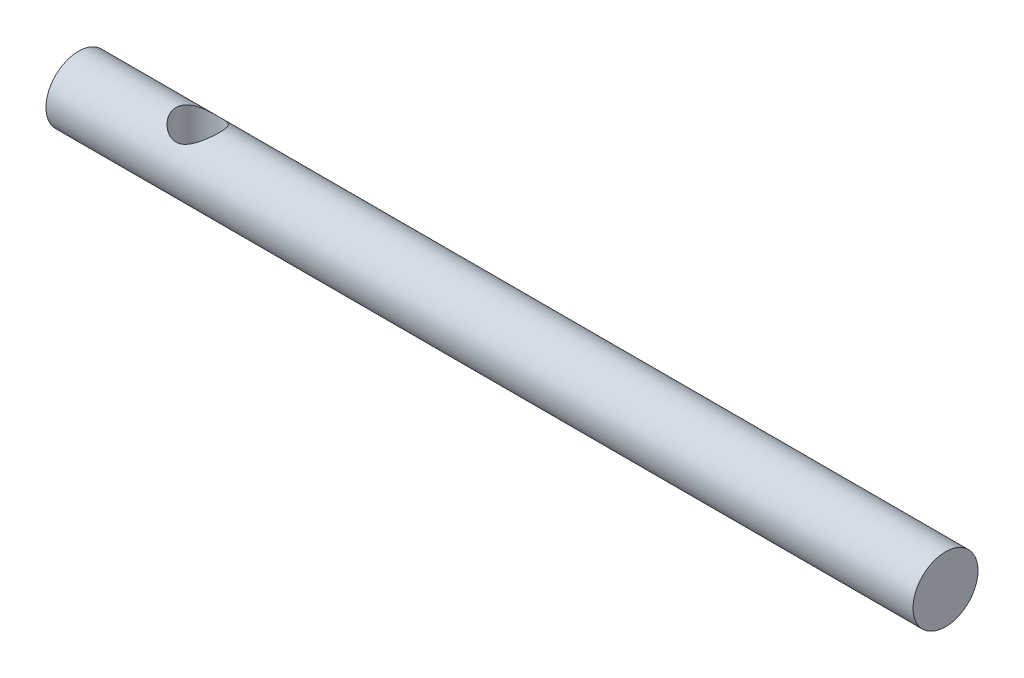
from build123d import *

# Parameters (mm, degrees)
SKETCH1_R               = 1.5
BOSS_EXTRUDE1_DEPTH     = 40
SKETCH2_R               = 1
CUT_EXTRUDE1_DEPTH      = 2.5
CUT_EXTRUDE1_DEPTH_BACK = 2.5


with BuildPart() as part:
    # Sketch1 → Boss-Extrude1 (new body)
    with BuildSketch(Plane(origin=(0, 0, 0), x_dir=(0, 0, -1), z_dir=(1, 0, 0))):
        Circle(SKETCH1_R)
    extrude(amount=BOSS_EXTRUDE1_DEPTH)

    # Sketch2 → Cut-Extrude1 (cut, two sides)
    with BuildSketch(Plane(origin=(0, 0, 0), x_dir=(1, 0, 0), z_dir=(0, 1, 0))) as cut_extrude1_sk:
        with Locations((5.5, 0)):
            Circle(SKETCH2_R)
    extrude(amount=CUT_EXTRUDE1_DEPTH, mode=Mode.SUBTRACT)
    extrude(cut_extrude1_sk.sketch, amount=-CUT_EXTRUDE1_DEPTH_BACK, mode=Mode.SUBTRACT)


solid = part.part
